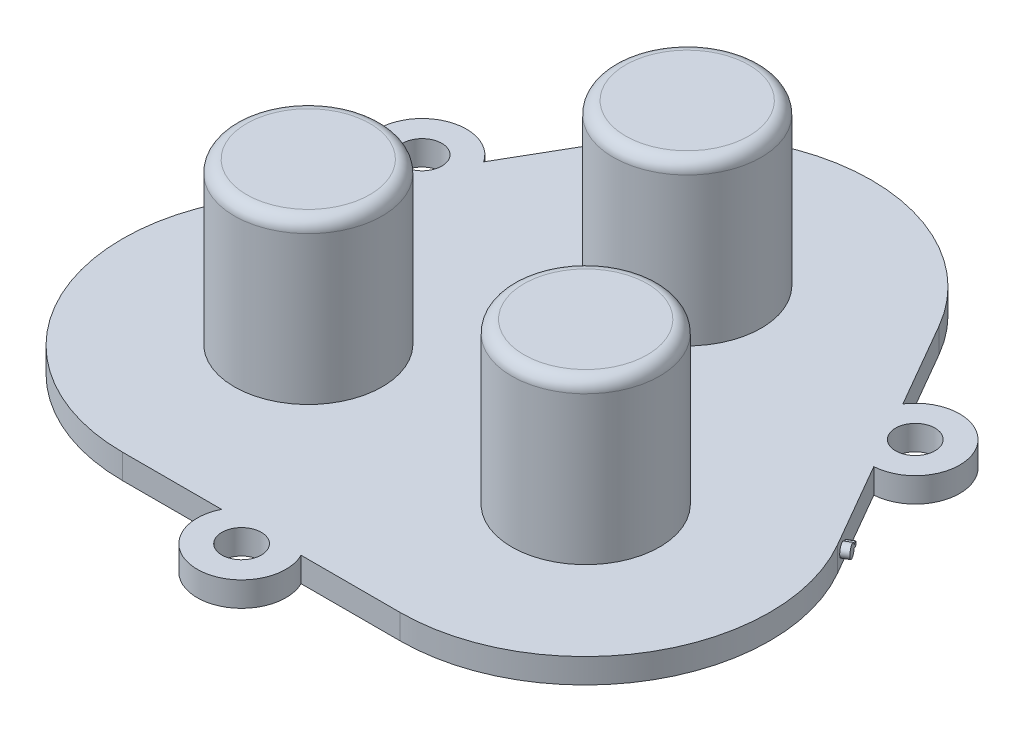
from build123d import *

# Parameters (mm, degrees)
SKETCH5_R           = 1.6
BOSS_EXTRUDE2_DEPTH = 2
SKETCH6_R           = 6
BOSS_EXTRUDE3_DEPTH = 15
FILLET1_R           = 1
BOSS_EXTRUDE5_DEPTH = 0.6


with BuildPart() as part:
    # Sketch5 → Boss-Extrude2 (new body)
    with BuildSketch(Plane(origin=(0, 0, 0), x_dir=(1, 0, 0), z_dir=(0, 1, 0))):
        with BuildLine():
            Line((-11.250000051, -22.142785594), (-3.22490315, -22.142785594))
            ThreePointArc((-3.22490315, -22.142785594), (-5.1e-08, -27.342785594), (3.224903048, -22.142785594))
            Line((3.224903048, -22.142785594), (11.249999949, -22.142785594))
            ThreePointArc((11.249999949, -22.142785594), (24.240381006, -14.642785594), (24.240381006, 0.357214406))
            Line((24.240381006, 0.357214406), (20.227832555, 7.30715219))
            ThreePointArc((20.227832555, 7.30715219), (23.118713105, 12.700000199), (17.002929456, 12.892848208))
            Line((17.002929456, 12.892848208), (12.990381006, 19.842785992))
            ThreePointArc((12.990381006, 19.842785992), (-5.1e-08, 27.342785992), (-12.990381108, 19.842785992))
            Line((-12.990381108, 19.842785992), (-17.002929558, 12.892848208))
            ThreePointArc((-17.002929558, 12.892848208), (-23.118713208, 12.700000199), (-20.227832658, 7.30715219))
            Line((-20.227832658, 7.30715219), (-24.240381108, 0.357214406))
            ThreePointArc((-24.240381108, 0.357214406), (-24.240381108, -14.642785594), (-11.250000051, -22.142785594))
        make_face()
        with Locations((20.001021652, 10.900000199)):
            Circle(SKETCH5_R, mode=Mode.SUBTRACT)
        with Locations((-5.1e-08, -23.742785594)):
            Circle(SKETCH5_R, mode=Mode.SUBTRACT)
        with Locations((-20.001021754, 10.900000199)):
            Circle(SKETCH5_R, mode=Mode.SUBTRACT)
    extrude(amount=BOSS_EXTRUDE2_DEPTH)

    # Sketch6 → Boss-Extrude3 (add)
    with BuildSketch(Plane(origin=(0, 0, 0), x_dir=(1, 0, 0), z_dir=(0, 1, 0))):
        with Locations((-0.060025126, 12.462836141)):
            Circle(SKETCH6_R)
        with Locations((11.189974874, -7.022735444)):
            Circle(SKETCH6_R)
        with Locations((-11.310025126, -7.022735444)):
            Circle(SKETCH6_R)
    extrude(amount=BOSS_EXTRUDE3_DEPTH)

    # Fillet1
    fillet1_edges = [part.edges().sort_by_distance(p)[0] for p in [
        (-6.060025126, 15, -12.462836141),
        (5.189974874, 15, 7.022735444),
        (-17.310025126, 15, 7.022735444),
    ]]
    fillet(fillet1_edges, radius=FILLET1_R)

    # Sketch7 → Boss-Extrude5 (add)
    with BuildSketch(Plane(origin=(18.334964129, 0, -10.585696476), x_dir=(-0.5, 0, -0.866025404), z_dir=(0.866025404, 0, -0.5))):
        with BuildLine():
            ThreePointArc((-10.342014969, 1.052839651), (-11.339215101, 1), (-10.342014969, 0.947160349))
            ThreePointArc((-10.342014969, 0.947160349), (-9.94912129, 1), (-10.342014969, 1.052839651))
        make_face()
    extrude(amount=BOSS_EXTRUDE5_DEPTH)


solid = part.part
